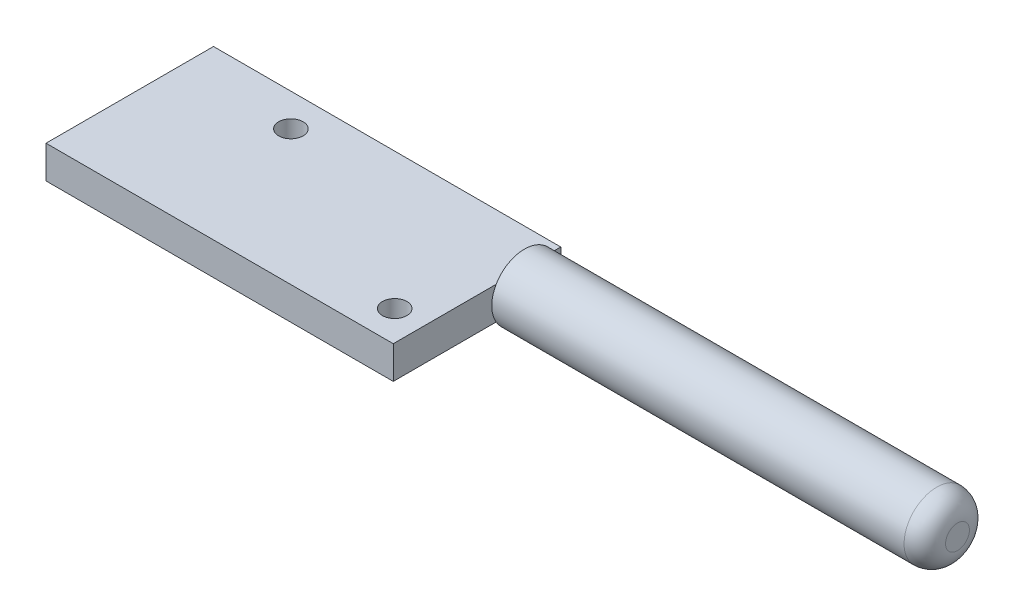
from build123d import *

# Parameters (mm, degrees)
SKETCH1_W           = 42.5
SKETCH1_H           = 20.5
BOSS_EXTRUDE1_DEPTH = 4
SKETCH2_R           = 4
BOSS_EXTRUDE2_DEPTH = 53
FILLET1_R           = 2.54
SKETCH4_R           = 1.5
CUT_EXTRUDE2_DEPTH  = 7.0000001


with BuildPart() as part:
    # Sketch1 → Boss-Extrude1 (new body)
    with BuildSketch(Plane(origin=(0, 0, 0), x_dir=(1, 0, 0), z_dir=(0, 1, 0))):
        Rectangle(SKETCH1_W, SKETCH1_H)
    extrude(amount=BOSS_EXTRUDE1_DEPTH)

    # Sketch2 → Boss-Extrude2 (add)
    with BuildSketch(Plane(origin=(21.25, 0, 0), x_dir=(0, 0, -1), z_dir=(1, 0, 0))):
        with Locations((5.804410425, 2)):
            Circle(SKETCH2_R)
    extrude(amount=BOSS_EXTRUDE2_DEPTH)

    # Fillet1
    fillet1_edges = [part.edges().sort_by_distance(p)[0] for p in [
        (74.25, 2, -1.804410425),
    ]]
    fillet(fillet1_edges, radius=FILLET1_R)

    # Sketch4 → Cut-Extrude2 (cut, through all)
    with BuildSketch(Plane(origin=(0, 4, 0), x_dir=(1, 0, 0), z_dir=(0, 1, 0))):
        with Locations((17.612, -6.44)):
            Circle(SKETCH4_R)
        with Locations((-7.788, 6.26)):
            Circle(SKETCH4_R)
    extrude(amount=-CUT_EXTRUDE2_DEPTH, mode=Mode.SUBTRACT)


solid = part.part
